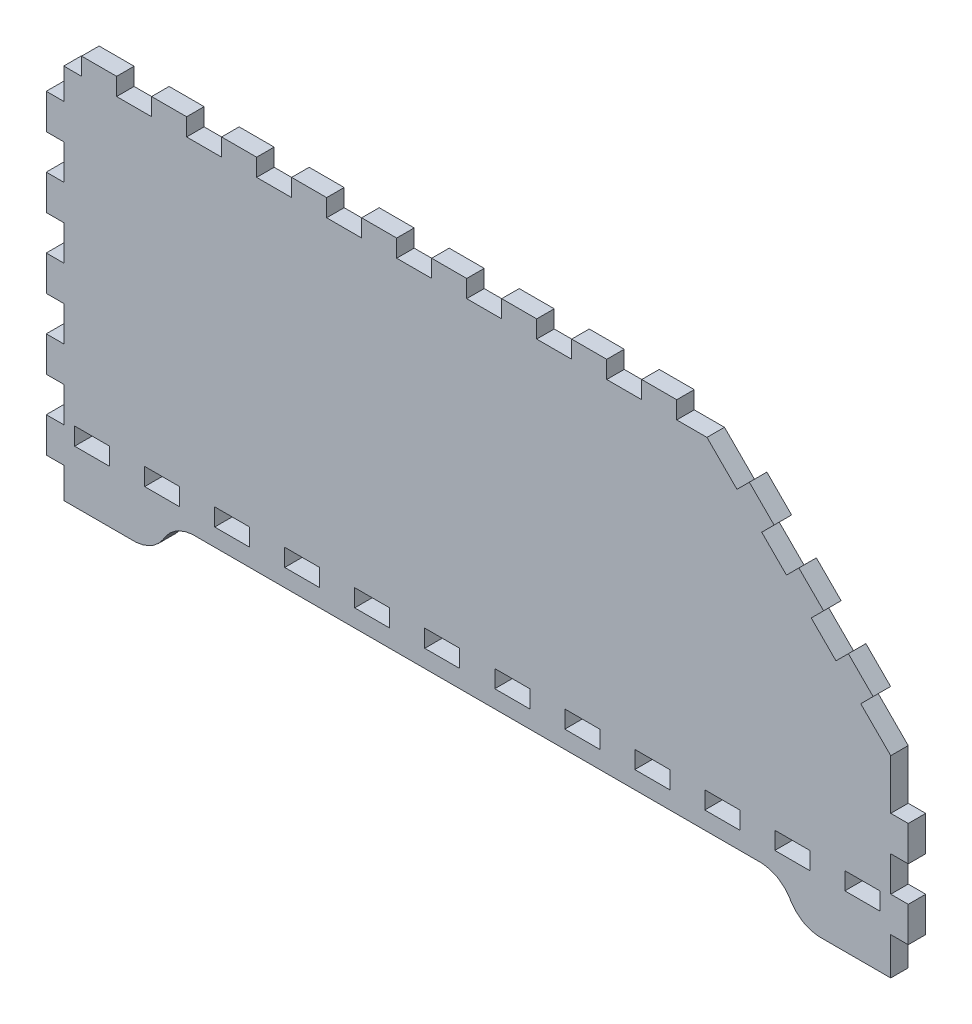
from build123d import *

# Parameters (mm, degrees)
BOSS_EXTRUDE1_DEPTH = 5.715


with BuildPart() as part:
    # Model → Boss-Extrude1 (new body)
    with BuildSketch(Plane.XY):
        Polygon((16.114776, 23.2006394), (38.974776, 23.2006394), (39.713662, 23.2006394), (41.932098, 23.590631), (44.254166, 24.4808502), (44.689776, 24.7316498), (45.123862, 24.983821), (47.05604, 26.54935), (48.622712, 28.481274), (48.87341, 28.91536), (49.124362, 29.350716), (50.690018, 31.282894), (52.621688, 32.848296), (53.057044, 33.098994), (53.491384, 33.349946), (55.813198, 34.241486), (58.031888, 34.630106), (58.772044, 34.630106), (243.457984, 34.630106), (244.196616, 34.630106), (246.415306, 34.241486), (248.737374, 33.349946), (249.172476, 33.098994), (249.606816, 32.848296), (251.53874, 31.282894), (253.105666, 29.350716), (253.356618, 28.91536), (253.607316, 28.481274), (255.17348, 26.54935), (257.10388, 24.983821), (257.54076, 24.7316498), (257.9751, 24.4808502), (260.29666, 23.590631), (262.51408, 23.2006394), (263.25576, 23.2006394), (286.11576, 23.2006394), (286.11576, 35.465004), (291.83076, 35.465004), (291.83076, 46.89475), (286.11576, 46.89475), (286.11576, 58.323988), (291.83076, 58.323988), (291.83076, 69.75475), (286.11576, 69.75475), (286.11576, 86.061296), (276.32152, 95.855028), (280.36266, 99.896676), (272.28038, 107.978956), (268.2367, 103.937054), (260.15442, 112.019334), (264.1981, 116.060982), (256.11582, 124.141738), (252.07341, 120.10136), (243.992654, 128.18364), (248.033032, 132.224272), (239.951006, 140.307822), (235.909104, 136.266174), (226.115372, 146.060922), (216.248488, 146.060922), (216.248488, 151.775668), (204.81925, 151.775668), (204.81925, 146.060922), (193.388488, 146.060922), (193.388488, 151.775668), (181.958996, 151.775668), (181.958996, 146.060922), (170.529504, 146.060922), (170.529504, 151.775668), (159.098488, 151.775668), (159.098488, 146.060922), (147.66925, 146.060922), (147.66925, 151.775668), (136.238488, 151.775668), (136.238488, 146.060922), (124.808996, 146.060922), (124.808996, 151.775668), (113.379504, 151.775668), (113.379504, 146.060922), (101.948488, 146.060922), (101.948488, 151.775668), (90.51925, 151.775668), (90.51925, 146.060922), (79.088488, 146.060922), (79.088488, 151.775668), (67.658996, 151.775668), (67.658996, 146.060922), (56.229504, 146.060922), (56.229504, 151.775668), (44.798488, 151.775668), (44.798488, 146.060922), (33.36925, 146.060922), (33.36925, 151.775668), (21.938361, 151.775668), (21.938361, 146.060922), (16.114776, 146.060922), (16.114776, 136.066022), (10.4000554, 136.066022), (10.4000554, 124.63526), (16.114776, 124.63526), (16.114776, 113.205768), (10.4000554, 113.205768), (10.4000554, 101.775006), (16.114776, 101.775006), (16.114776, 90.345768), (10.4000554, 90.345768), (10.4000554, 78.916022), (16.114776, 78.916022), (16.114776, 67.48526), (10.4000554, 67.48526), (10.4000554, 56.055768), (16.114776, 56.055768), (16.114776, 44.625006), (10.4000554, 44.625006), (10.4000554, 33.195514), (16.114776, 33.195514), align=None)
        Polygon((25.3848362, 40.346122), (19.6701156, 40.346122), (19.6701156, 46.060868), (31.099506, 46.060868), (31.099506, 40.346122), align=None, mode=Mode.SUBTRACT)
        Polygon((48.245268, 40.346122), (42.530522, 40.346122), (42.530522, 46.060868), (53.95976, 46.060868), (53.95976, 40.346122), align=None, mode=Mode.SUBTRACT)
        Polygon((71.105522, 40.346122), (65.390522, 40.346122), (65.390522, 46.060868), (76.820268, 46.060868), (76.820268, 40.346122), align=None, mode=Mode.SUBTRACT)
        Polygon((93.965522, 40.346122), (88.249506, 40.346122), (88.249506, 46.060868), (99.680522, 46.060868), (99.680522, 40.346122), align=None, mode=Mode.SUBTRACT)
        Polygon((116.824506, 40.346122), (111.10976, 40.346122), (111.10976, 46.060868), (122.540522, 46.060868), (122.540522, 40.346122), align=None, mode=Mode.SUBTRACT)
        Polygon((139.68476, 40.346122), (133.970268, 40.346122), (133.970268, 46.060868), (145.399506, 46.060868), (145.399506, 40.346122), align=None, mode=Mode.SUBTRACT)
        Polygon((162.545268, 40.346122), (156.830522, 40.346122), (156.830522, 46.060868), (168.25976, 46.060868), (168.25976, 40.346122), align=None, mode=Mode.SUBTRACT)
        Polygon((185.405522, 40.346122), (179.690522, 40.346122), (179.690522, 46.060868), (191.120268, 46.060868), (191.120268, 40.346122), align=None, mode=Mode.SUBTRACT)
        Polygon((208.265522, 40.346122), (202.549506, 40.346122), (202.549506, 46.060868), (213.980522, 46.060868), (213.980522, 40.346122), align=None, mode=Mode.SUBTRACT)
        Polygon((231.124506, 40.346122), (225.40976, 40.346122), (225.40976, 46.060868), (236.840522, 46.060868), (236.840522, 40.346122), align=None, mode=Mode.SUBTRACT)
        Polygon((253.98476, 40.346122), (248.270268, 40.346122), (248.270268, 46.060868), (259.69976, 46.060868), (259.69976, 40.346122), align=None, mode=Mode.SUBTRACT)
        Polygon((276.84476, 40.346122), (271.12976, 40.346122), (271.12976, 46.060868), (282.55976, 46.060868), (282.55976, 40.346122), align=None, mode=Mode.SUBTRACT)
    extrude(amount=BOSS_EXTRUDE1_DEPTH)


solid = part.part
